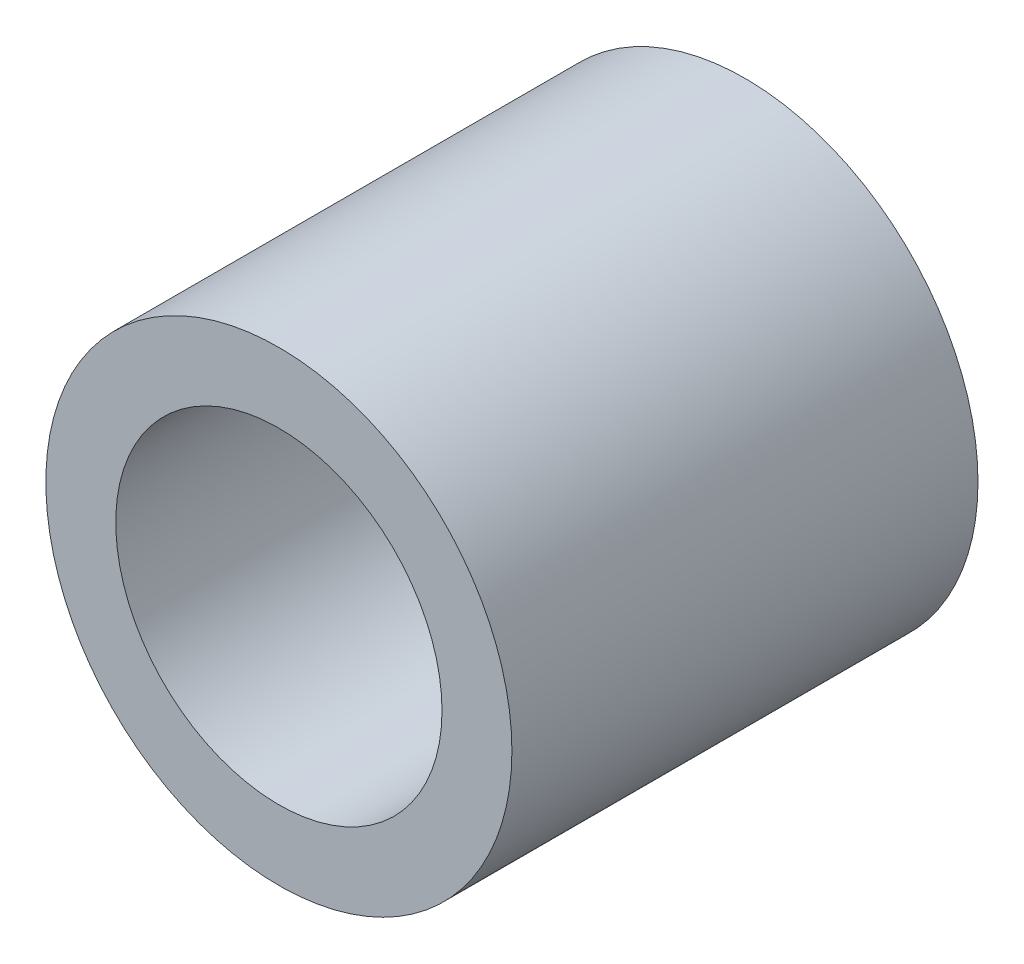
from build123d import *

# Parameters (mm, degrees)
SKETCH1_R           = 10
BOSS_EXTRUDE1_DEPTH = 20
SKETCH2_R           = 7
CUT_EXTRUDE1_DEPTH  = 35


with BuildPart() as part:
    # Sketch1 → Boss-Extrude1 (new body)
    with BuildSketch(Plane.XY):
        Circle(SKETCH1_R)
    extrude(amount=BOSS_EXTRUDE1_DEPTH)

    # Sketch2 → Cut-Extrude1 (cut)
    with BuildSketch(Plane.XY):
        Circle(SKETCH2_R)
    extrude(amount=CUT_EXTRUDE1_DEPTH, mode=Mode.SUBTRACT)


solid = part.part
